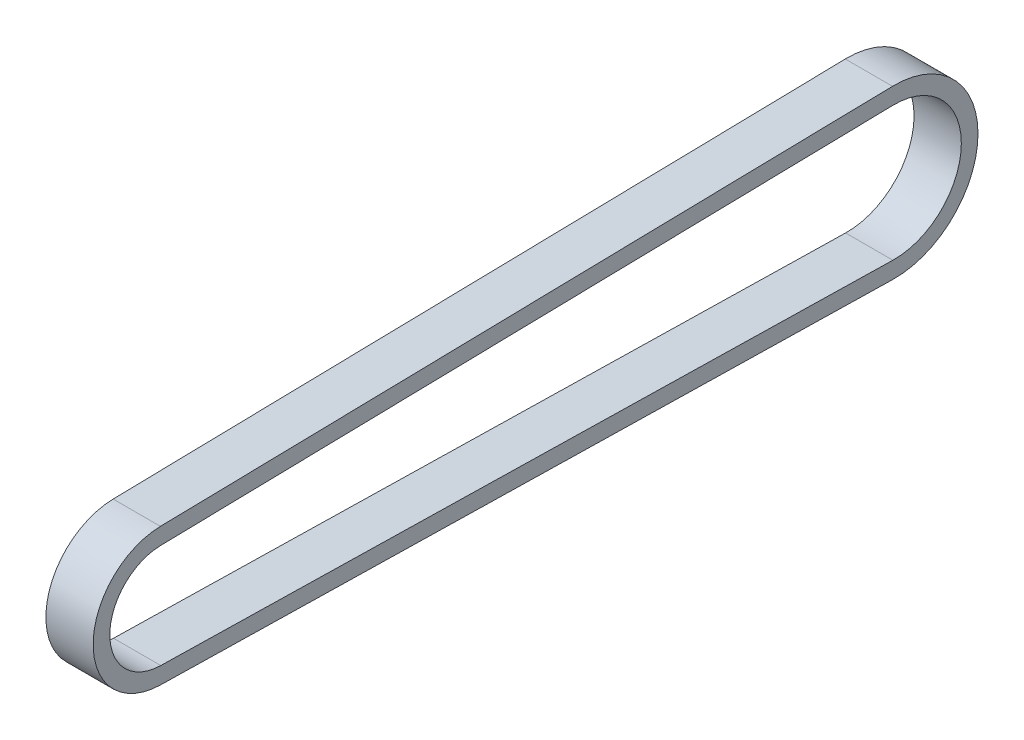
from build123d import *

# Parameters (mm, degrees)
BOSS_EXTRUDE1_DEPTH = 4.5


with BuildPart() as part:
    # Sketch1 → Boss-Extrude1 (new body, symmetric)
    with BuildSketch(Plane(origin=(0, 0, 0), x_dir=(0, 0, -1), z_dir=(1, 0, 0))):
        with BuildLine():
            Line((-0.268771319, 13.080779064), (139.143771363, 15.945294455))
            ThreePointArc((139.143771363, 15.945294455), (155.42006, 0), (139.143771363, -15.945294455))
            Line((139.143771363, -15.945294455), (-0.268771319, -13.080779064))
            ThreePointArc((-0.268771319, -13.080779064), (-13.08354, 0), (-0.268771319, 13.080779064))
        make_face()
        with BuildLine():
            Line((-0.203548227, 9.906449064), (139.208994455, 12.770964456))
            ThreePointArc((139.208994455, 12.770964456), (152.24506, 0), (139.208994455, -12.770964456))
            Line((139.208994455, -12.770964456), (-0.203548227, -9.906449064))
            ThreePointArc((-0.203548227, -9.906449064), (-9.90854, 0), (-0.203548227, 9.906449064))
        make_face(mode=Mode.SUBTRACT)
    extrude(amount=BOSS_EXTRUDE1_DEPTH, both=True)


solid = part.part
